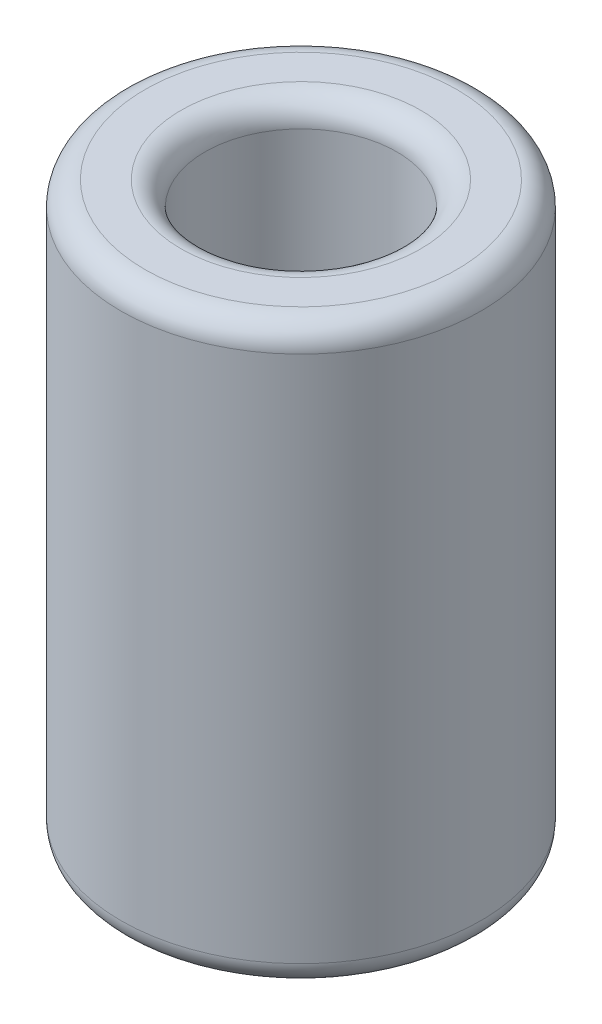
from build123d import *

# Parameters (mm, degrees)
SKETCH1_R           = 7.5
SKETCH1_R_2         = 4
BOSS_EXTRUDE1_DEPTH = 24
FILLET2_R           = 1


with BuildPart() as part:
    # Sketch1 → Boss-Extrude1 (new body)
    with BuildSketch(Plane(origin=(0, 0, 0), x_dir=(1, 0, 0), z_dir=(0, 1, 0))):
        with Locations(Location((0, 0, 0), (0, 0, 270))):  # turned: the seam where the file's is
            Circle(SKETCH1_R)
        with Locations(Location((0, 0, 0), (0, 0, 270))):  # turned: the seam where the file's is
            Circle(SKETCH1_R_2, mode=Mode.SUBTRACT)
    extrude(amount=BOSS_EXTRUDE1_DEPTH)

    # Fillet2
    fillet2_edges = [part.edges().sort_by_distance(p)[0] for p in [
        (0, 0, -7.5),
        (0, 24, -7.5),
        (0, 0, -4),
        (0, 24, -4),
    ]]
    fillet(fillet2_edges, radius=FILLET2_R)


solid = part.part
